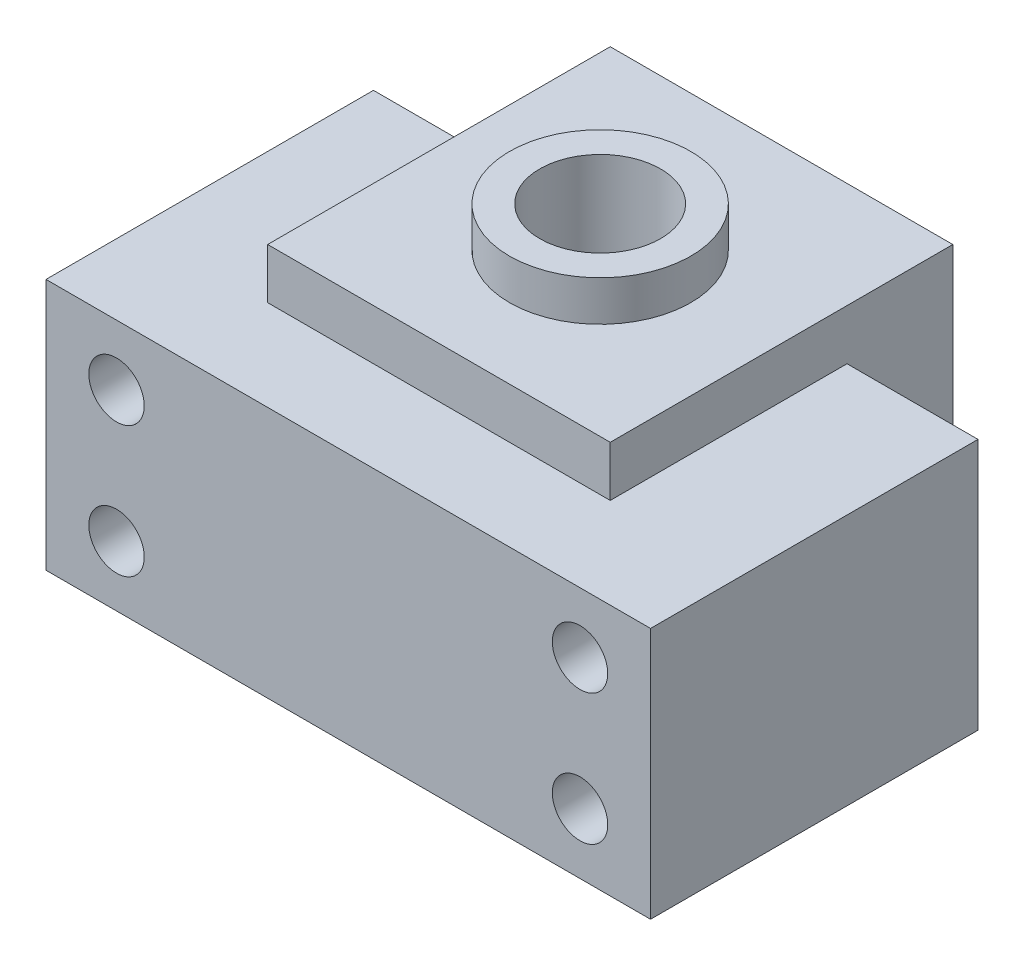
from build123d import *

# Parameters (mm, degrees)
SKETCH1_R           = 6
BOSS_EXTRUDE1_DEPTH = 25
SKETCH2_R           = 2.75
CUT_EXTRUDE1_DEPTH  = 33.5
SKETCH3_W           = 34
SKETCH3_H           = 34
SKETCH3_R           = 6
BOSS_EXTRUDE2_DEPTH = 5
SKETCH4_R           = 9
SKETCH4_R_2         = 6
BOSS_EXTRUDE3_DEPTH = 4


with BuildPart() as part:
    # Sketch1 → Boss-Extrude1 (new body)
    with BuildSketch(Plane(origin=(0, 0, 0), x_dir=(1, 0, 0), z_dir=(0, 1, 0))):
        Polygon((30, -21.5), (-30, -21.5), (-30, 11), (-17, 11), (-17, 21.5), (17, 21.5), (17, 11), (30, 11), align=None)
        with Locations((0, 3.5)):
            Circle(SKETCH1_R, mode=Mode.SUBTRACT)
    extrude(amount=BOSS_EXTRUDE1_DEPTH)

    # Sketch2 → Cut-Extrude1 (cut, through all)
    with BuildSketch(Plane(origin=(0, 0, -11), x_dir=(-1, 0, 0), z_dir=(0, 0, -1))):
        with Locations((-23, 19)):
            Circle(SKETCH2_R)
        with Locations((-23, 6)):
            Circle(SKETCH2_R)
        with Locations((23, 6)):
            Circle(SKETCH2_R)
        with Locations((23, 19)):
            Circle(SKETCH2_R)
    extrude(amount=-CUT_EXTRUDE1_DEPTH, mode=Mode.SUBTRACT)

    # Sketch3 → Boss-Extrude2 (add)
    with BuildSketch(Plane(origin=(0, 25, 0), x_dir=(1, 0, 0), z_dir=(0, 1, 0))):
        with Locations((0, 4.5)):
            Rectangle(SKETCH3_W, SKETCH3_H)
        with Locations((0, 3.5)):
            Circle(SKETCH3_R, mode=Mode.SUBTRACT)
    extrude(amount=BOSS_EXTRUDE2_DEPTH)

    # Sketch4 → Boss-Extrude3 (add)
    with BuildSketch(Plane(origin=(0, 30, 0), x_dir=(1, 0, 0), z_dir=(0, 1, 0))):
        with Locations((0, 3.5)):
            Circle(SKETCH4_R)
        with Locations((0, 3.5)):
            Circle(SKETCH4_R_2, mode=Mode.SUBTRACT)
    extrude(amount=BOSS_EXTRUDE3_DEPTH)


solid = part.part
